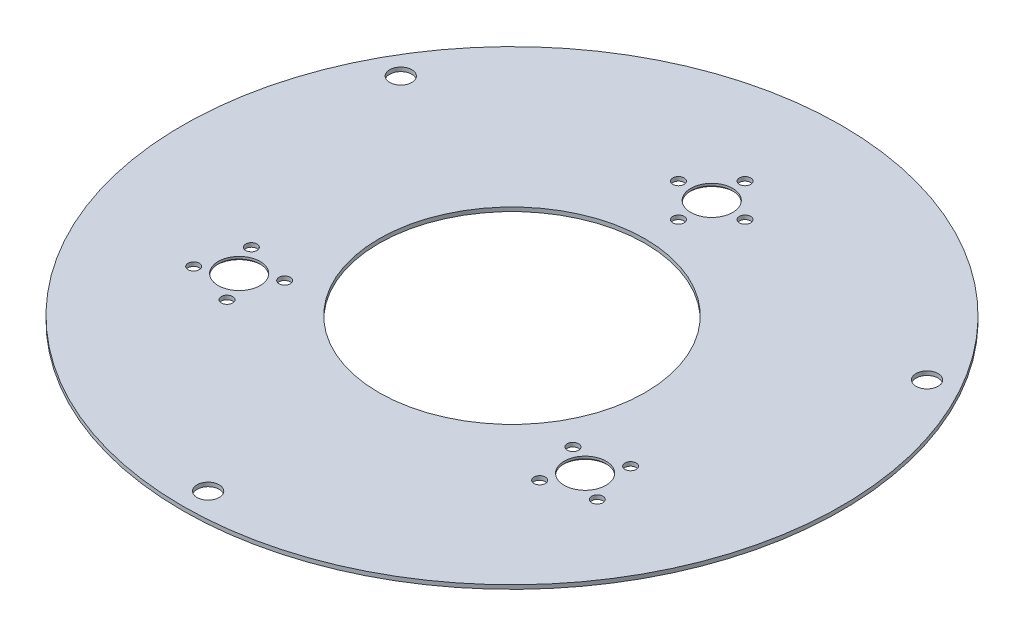
from build123d import *

# Parameters (mm, degrees)
SKETCH1_R                                = 125.73
SKETCH1_R_2                              = 50.8
EXTRUDE1_DEPTH                           = 1.524
F_5_16_CLEARANCE_HOLE1_D                 = 8.4328
CIRPATTERN1_COUNT                        = 3
F_1_4_20_WELD_NUT_CIRPATTERN_COUNT       = 3
HOLE_FOR_5_16_18_WELD_NUT_D              = 15.9766
HOLE_FOR_5_16_18_WELD_NUT_DEPTH          = 21.59
F_5_16_18_WELD_NUT_HOLE_CIRPATTERN_COUNT = 3
CHAMFER4_SIZE                            = 0.635
F_6_CLEARANCE_HOLE1_D                    = 4.3053
CIRPATTERN2_COUNT                        = 4
CIRPATTERN3_COUNT                        = 3
CIRPATTERN3_COPY_1_D                     = 4.3053
CIRPATTERN3_COPY_2_D                     = 4.3053
CIRPATTERN3_COPY_3_D                     = 4.3053
CIRPATTERN3_COPY_4_D                     = 4.3053
CIRPATTERN3_COPY_5_D                     = 4.3053
CIRPATTERN3_COPY_6_D                     = 4.3053


with BuildPart() as part:
    # Sketch1 → Extrude1 (new body)
    with BuildSketch(Plane(origin=(0, 0, 0), x_dir=(1, 0, 0), z_dir=(0, 1, 0))):
        with Locations(Location((0, 0, 0), (0, 0, 270))):  # turned: the seam where the file's is
            Circle(SKETCH1_R)
        with Locations(Location((0, 0, 0), (0, 0, 270))):  # turned: the seam where the file's is
            Circle(SKETCH1_R_2, mode=Mode.SUBTRACT)
    extrude(amount=EXTRUDE1_DEPTH)

    # 5_16 Clearance Hole1 (through all)
    with Locations(Plane(origin=(0, 1.524, 0), x_dir=(-1, 0, 0), z_dir=(0, 1, 0))):
        with Locations((0, 115.9256)):
            f_5_16_clearance_hole1 = Hole(F_5_16_CLEARANCE_HOLE1_D / 2)

    # CirPattern1: 5_16 Clearance Hole1 ×3 about axis
    cirpattern1_axis = Axis((0, 0, 0), (0, 1, 0))
    for i in range(1, CIRPATTERN1_COUNT):
        add(f_5_16_clearance_hole1.rotate(cirpattern1_axis, i * 360 / CIRPATTERN1_COUNT), mode=Mode.SUBTRACT)

    # Sketch4 → Hole For 1_4_-20 Weld Nut (revolve, cut)
    with BuildSketch(Plane(origin=(0, 1.524, -76.2), x_dir=(0, 0, 1), z_dir=(1, 0, 0))):
        Polygon((0, 0), (0, 16.54598865), (6.4008, 12.7), (6.4008, 0), align=None)
    hole_for_1_4_20_weld_nut = revolve(axis=Axis((0, 7.874, -76.2), (0, -1, 0)), mode=Mode.SUBTRACT)

    # 1_4_-20 Weld Nut CirPattern: Hole For 1_4_-20 Weld Nut ×3 about axis
    f_1_4_20_weld_nut_cirpattern_axis = Axis((0, 0, 0), (0, 1, 0))
    for i in range(1, F_1_4_20_WELD_NUT_CIRPATTERN_COUNT):
        add(hole_for_1_4_20_weld_nut.rotate(f_1_4_20_weld_nut_cirpattern_axis, i * 360 / F_1_4_20_WELD_NUT_CIRPATTERN_COUNT), mode=Mode.SUBTRACT)

    # Hole For 5_16_-18 Weld Nut
    with Locations(Plane(origin=(0, 1.524, 0), x_dir=(-1, 0, 0), z_dir=(0, 1, 0))):
        with Locations((0, -76.2)):
            hole_for_5_16_18_weld_nut = Hole(HOLE_FOR_5_16_18_WELD_NUT_D / 2, depth=HOLE_FOR_5_16_18_WELD_NUT_DEPTH)

    # 5_16_-18 Weld Nut Hole CirPattern: Hole For 5_16_-18 Weld Nut ×3 about axis
    f_5_16_18_weld_nut_hole_cirpattern_axis = Axis((0, 0, 0), (0, 1, 0))
    for i in range(1, F_5_16_18_WELD_NUT_HOLE_CIRPATTERN_COUNT):
        add(hole_for_5_16_18_weld_nut.rotate(f_5_16_18_weld_nut_hole_cirpattern_axis, i * 360 / F_5_16_18_WELD_NUT_HOLE_CIRPATTERN_COUNT), mode=Mode.SUBTRACT)

    # Chamfer4
    chamfer4_edges = [part.edges().sort_by_distance(p)[0] for p in [
        (-7.9883, 0, -76.2),
        (69.985285768, 0, 31.181929267),
        (-61.996985768, 0, 45.018070733),
    ]]
    chamfer(chamfer4_edges, length=CHAMFER4_SIZE)

    # 6 Clearance Hole1 (through all)
    with Locations(Plane.XZ):
        with Locations((-54.99261314, 31.75)):
            f_6_clearance_hole1 = Hole(F_6_CLEARANCE_HOLE1_D / 2)

    # CirPattern2: 6 Clearance Hole1 ×4 about axis
    cirpattern2_axis = Axis((-65.991135768, 0, 38.1), (0, 1, 0))
    for i in range(1, CIRPATTERN2_COUNT):
        add(f_6_clearance_hole1.rotate(cirpattern2_axis, i * 360 / CIRPATTERN2_COUNT), mode=Mode.SUBTRACT)

    # CirPattern3: 6 Clearance Hole1 ×3 about axis
    cirpattern3_axis = Axis((0, 0, 0), (0, 1, 0))
    for i in range(1, CIRPATTERN3_COUNT):
        add(f_6_clearance_hole1.rotate(cirpattern3_axis, i * 360 / CIRPATTERN3_COUNT), mode=Mode.SUBTRACT)

    # CirPattern3 copy 1 (through all)
    with Locations(Plane(origin=(27.891135768, 0, 104.091135768), x_dir=(-0.866025404, 0, 0.5), z_dir=(0, -1, 0))):
        with Locations((-54.99261314, 31.75)):
            Hole(CIRPATTERN3_COPY_1_D / 2)

    # CirPattern3 copy 2 (through all)
    with Locations(Plane(origin=(76.2, 0, -76.2), x_dir=(0.866025404, 0, 0.5), z_dir=(0, -1, 0))):
        with Locations((-54.99261314, 31.75)):
            Hole(CIRPATTERN3_COPY_2_D / 2)

    # CirPattern3 copy 3 (through all)
    with Locations(Plane(origin=(131.982271537, 0, 76.2), x_dir=(0.5, 0, 0.866025404), z_dir=(0, -1, 0))):
        with Locations((-54.99261314, 31.75)):
            Hole(CIRPATTERN3_COPY_3_D / 2)

    # CirPattern3 copy 4 (through all)
    with Locations(Plane(origin=(0, 0, -152.4), x_dir=(0.5, 0, -0.866025404), z_dir=(0, -1, 0))):
        with Locations((-54.99261314, 31.75)):
            Hole(CIRPATTERN3_COPY_4_D / 2)

    # CirPattern3 copy 5 (through all)
    with Locations(Plane(origin=(104.091135768, 0, -27.891135768), x_dir=(0.866025404, 0, -0.5), z_dir=(0, -1, 0))):
        with Locations((-54.99261314, 31.75)):
            Hole(CIRPATTERN3_COPY_5_D / 2)

    # CirPattern3 copy 6 (through all)
    with Locations(Plane(origin=(-76.2, 0, -76.2), x_dir=(-0.866025404, 0, -0.5), z_dir=(0, -1, 0))):
        with Locations((-54.99261314, 31.75)):
            Hole(CIRPATTERN3_COPY_6_D / 2)


solid = part.part
